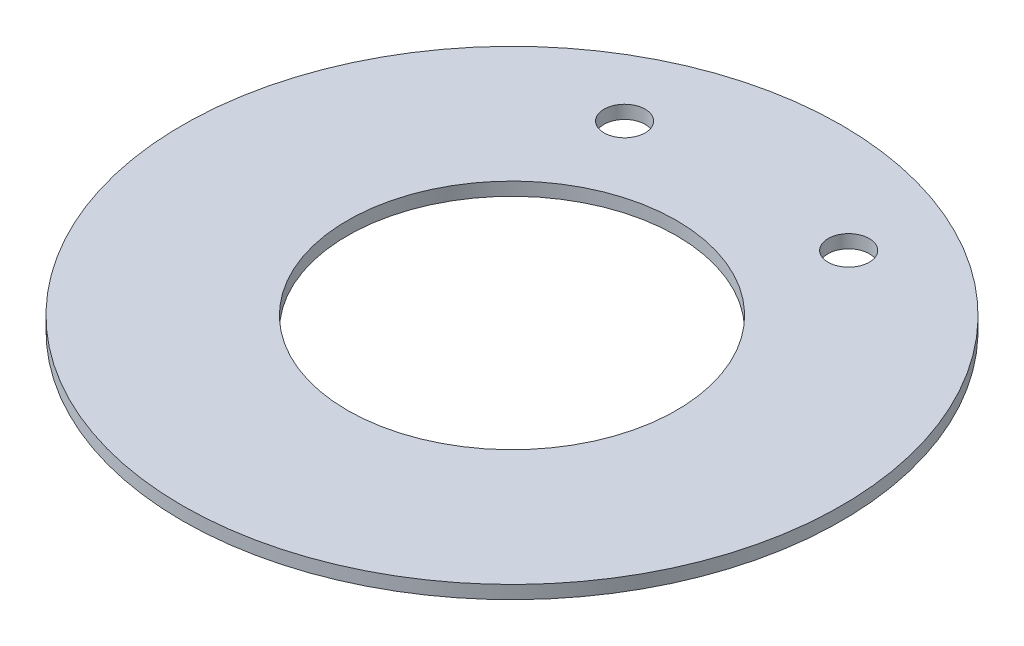
from build123d import *

# Parameters (mm, degrees)
SKETCH1_R           = 79.375
SKETCH1_R_2         = 39.624
BOSS_EXTRUDE1_DEPTH = 3.175
SKETCH2_R           = 4.953
CUT_EXTRUDE2_DEPTH  = 4.175


with BuildPart() as part:
    # Sketch1 → Boss-Extrude1 (new body)
    with BuildSketch(Plane(origin=(0, 0, 0), x_dir=(1, 0, 0), z_dir=(0, 1, 0))):
        Circle(SKETCH1_R)
        Circle(SKETCH1_R_2, mode=Mode.SUBTRACT)
    extrude(amount=BOSS_EXTRUDE1_DEPTH)

    # Sketch2 → Cut-Extrude2 (cut, through all)
    with BuildSketch(Plane(origin=(0, 3.175, 0), x_dir=(1, 0, 0), z_dir=(0, 1, 0))):
        with Locations((26.9875, 54.102)):
            Circle(SKETCH2_R)
        with Locations((-26.9875, 54.102)):
            Circle(SKETCH2_R)
    extrude(amount=-CUT_EXTRUDE2_DEPTH, mode=Mode.SUBTRACT)


solid = part.part
